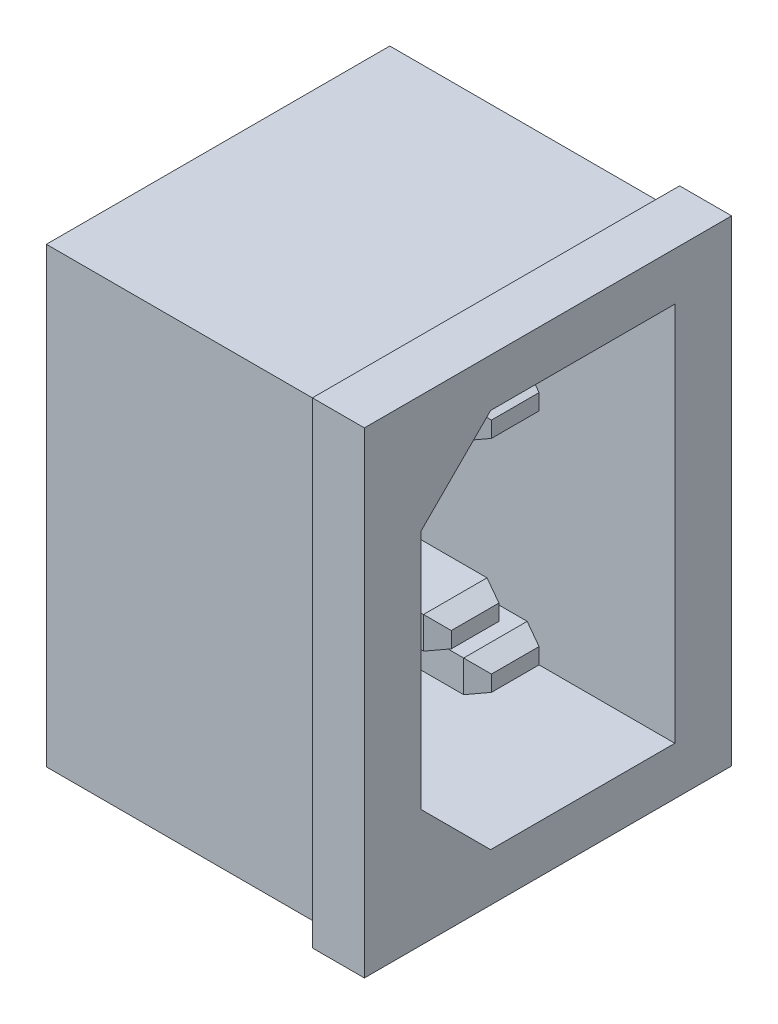
from build123d import *

# Parameters (mm, degrees)
SKETCH1_W             = 23.495
SKETCH1_H             = 30.48
BOSS_EXTRUDE1_DEPTH   = 3.3274
SKETCH2_W             = 21.971
SKETCH2_H             = 28.956
BOSS_EXTRUDE2_DEPTH   = 17.78
SKETCH3_W             = 16.2306
SKETCH3_H             = 24.3332
CUT_EXTRUDE1_DEPTH    = 16.51
CHAMFER1_SIZE         = 4.445
SKETCH4_W             = 4.064
SKETCH4_H             = 2.032
BOSS_EXTRUDE3_DEPTH   = 16.002
CHAMFER2_SIZE         = 1.27
CHAMFER2_SIZE2        = 0.508
CHAMFER2_PART_2_SIZE  = 1.27
CHAMFER2_PART_2_SIZE2 = 0.508
CHAMFER3_SIZE         = 1.27
CHAMFER3_SIZE2        = 0.508
CHAMFER3_PART_2_SIZE  = 1.27
CHAMFER3_PART_2_SIZE2 = 0.508
SKETCH5_W             = 4.064
SKETCH5_H             = 2.032
BOSS_EXTRUDE4_DEPTH   = 12.446
CHAMFER4_SIZE         = 1.27
CHAMFER4_SIZE2        = 0.508
CHAMFER4_PART_2_SIZE  = 1.27
CHAMFER4_PART_2_SIZE2 = 0.508
CHAMFER4_PART_3_SIZE  = 1.27
CHAMFER4_PART_3_SIZE2 = 0.508
CHAMFER4_PART_4_SIZE  = 1.27
CHAMFER4_PART_4_SIZE2 = 0.508
CHAMFER5_SIZE         = 0.508
CHAMFER5_SIZE2        = 1.27


with BuildPart() as part:
    # Sketch1 → Boss-Extrude1 (new body)
    with BuildSketch(Plane(origin=(0, 0, 0), x_dir=(0, 0, -1), z_dir=(1, 0, 0))):
        Rectangle(SKETCH1_W, SKETCH1_H)
    extrude(amount=BOSS_EXTRUDE1_DEPTH)

    # Sketch2 → Boss-Extrude2 (add)
    with BuildSketch(Plane.ZY):
        Rectangle(SKETCH2_W, SKETCH2_H)
    extrude(amount=BOSS_EXTRUDE2_DEPTH)

    # Sketch3 → Cut-Extrude1 (cut)
    with BuildSketch(Plane(origin=(3.3274, 0, 0), x_dir=(0, 0, -1), z_dir=(1, 0, 0))):
        Rectangle(SKETCH3_W, SKETCH3_H)
    extrude(amount=-CUT_EXTRUDE1_DEPTH, mode=Mode.SUBTRACT)

    # Chamfer1
    chamfer1_edges = [part.edges().sort_by_distance(p)[0] for p in [
        (-4.9276, -12.1666, 8.1153),
        (-4.9276, 12.1666, 8.1153),
    ]]
    chamfer(chamfer1_edges, length=CHAMFER1_SIZE)

    # Sketch4 → Boss-Extrude3 (add)
    with BuildSketch(Plane(origin=(2.8194, 0, 0), x_dir=(0, 0, -1), z_dir=(1, 0, 0))):
        with Locations((-4.155513801, 0.215773581)):
            Rectangle(SKETCH4_W, SKETCH4_H)
    extrude(amount=-BOSS_EXTRUDE3_DEPTH)

    # Chamfer2
    chamfer2_edges = [part.edges().sort_by_distance(p)[0] for p in [
        (2.8194, 1.231773581, 4.155513801),
    ]]
    chamfer2_side = [part.faces().sort_by_distance(p)[0] for p in [
        (-5.1816, 1.231773581, 4.155513801),
    ]]
    chamfer(chamfer2_edges, length=CHAMFER2_SIZE, length2=CHAMFER2_SIZE2, reference=chamfer2_side[0])

    # Chamfer2 part 2
    chamfer2_part_2_edges = [part.edges().sort_by_distance(p)[0] for p in [
        (2.8194, -0.800226419, 4.155513801),
    ]]
    chamfer2_part_2_side = [part.faces().sort_by_distance(p)[0] for p in [
        (-5.1816, -0.800226419, 4.155513801),
    ]]
    chamfer(chamfer2_part_2_edges, length=CHAMFER2_PART_2_SIZE, length2=CHAMFER2_PART_2_SIZE2, reference=chamfer2_part_2_side[0])

    # Chamfer3
    chamfer3_edges = [part.edges().sort_by_distance(p)[0] for p in [
        (2.8194, 0.215773581, 2.123513801),
    ]]
    chamfer3_side = [part.faces().sort_by_distance(p)[0] for p in [
        (-5.334994062, 0.215773581, 2.123513801),
    ]]
    chamfer(chamfer3_edges, length=CHAMFER3_SIZE, length2=CHAMFER3_SIZE2, reference=chamfer3_side[0])

    # Chamfer3 part 2
    chamfer3_part_2_edges = [part.edges().sort_by_distance(p)[0] for p in [
        (2.8194, 0.215773581, 6.187513801),
    ]]
    chamfer3_part_2_side = [part.faces().sort_by_distance(p)[0] for p in [
        (-5.334994062, 0.215773581, 6.187513801),
    ]]
    chamfer(chamfer3_part_2_edges, length=CHAMFER3_PART_2_SIZE, length2=CHAMFER3_PART_2_SIZE2, reference=chamfer3_part_2_side[0])

    # Sketch5 → Boss-Extrude4 (add)
    with BuildSketch(Plane(origin=(-0.7366, 0, 0), x_dir=(0, 0, -1), z_dir=(1, 0, 0))):
        with Locations((1.9685, 7.0358)):
            Rectangle(SKETCH5_W, SKETCH5_H)
    boss_extrude4 = extrude(amount=-BOSS_EXTRUDE4_DEPTH)

    # Chamfer4
    chamfer4_edges = [part.edges().sort_by_distance(p)[0] for p in [
        (-0.7366, 7.0358, -4.0005),
    ]]
    chamfer4_side = [part.faces().sort_by_distance(p)[0] for p in [
        (-6.9596, 7.0358, -4.0005),
    ]]
    chamfer(chamfer4_edges, length=CHAMFER4_SIZE, length2=CHAMFER4_SIZE2, reference=chamfer4_side[0])

    # Chamfer4 part 2
    chamfer4_part_2_edges = [part.edges().sort_by_distance(p)[0] for p in [
        (-0.7366, 8.0518, -1.9685),
    ]]
    chamfer4_part_2_side = [part.faces().sort_by_distance(p)[0] for p in [
        (-6.9596, 8.0518, -1.9685),
    ]]
    chamfer(chamfer4_part_2_edges, length=CHAMFER4_PART_2_SIZE, length2=CHAMFER4_PART_2_SIZE2, reference=chamfer4_part_2_side[0])

    # Chamfer4 part 3
    chamfer4_part_3_edges = [part.edges().sort_by_distance(p)[0] for p in [
        (-0.7366, 7.0358, 0.0635),
    ]]
    chamfer4_part_3_side = [part.faces().sort_by_distance(p)[0] for p in [
        (-6.9596, 7.0358, 0.0635),
    ]]
    chamfer(chamfer4_part_3_edges, length=CHAMFER4_PART_3_SIZE, length2=CHAMFER4_PART_3_SIZE2, reference=chamfer4_part_3_side[0])

    # Chamfer4 part 4
    chamfer4_part_4_edges = [part.edges().sort_by_distance(p)[0] for p in [
        (-0.7366, 6.0198, -1.9685),
    ]]
    chamfer4_part_4_side = [part.faces().sort_by_distance(p)[0] for p in [
        (-6.9596, 6.0198, -1.9685),
    ]]
    chamfer(chamfer4_part_4_edges, length=CHAMFER4_PART_4_SIZE, length2=CHAMFER4_PART_4_SIZE2, reference=chamfer4_part_4_side[0])

    # Mirror7: Boss-Extrude4 across plane
    add(boss_extrude4.mirror(Plane.ZX))

    # Chamfer5
    chamfer5_edges = [part.edges().sort_by_distance(p)[0] for p in [
        (-0.7366, -7.0358, -4.0005),
        (-0.7366, -8.0518, -1.9685),
        (-0.7366, -7.0358, 0.0635),
        (-0.7366, -6.0198, -1.9685),
    ]]
    chamfer5_side = [part.faces().sort_by_distance(p)[0] for p in [
        (-0.7366, -7.0358, -1.9685),
    ]]
    chamfer(chamfer5_edges, length=CHAMFER5_SIZE, length2=CHAMFER5_SIZE2, reference=chamfer5_side[0])


solid = part.part
